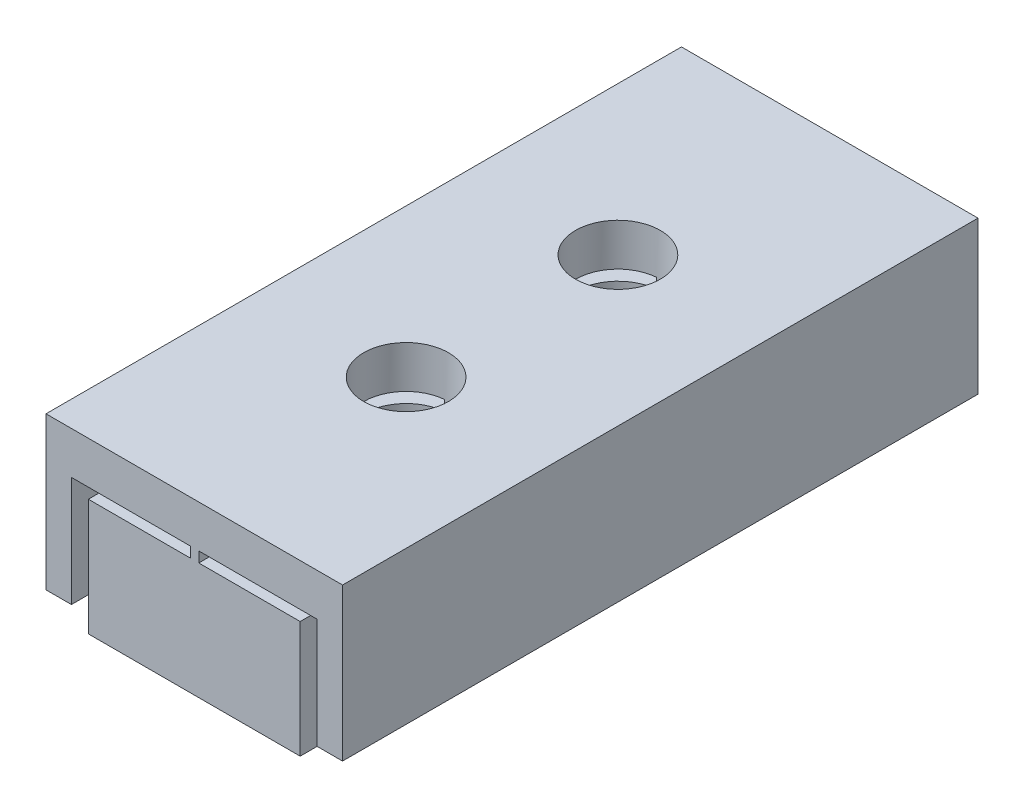
from build123d import *

# Parameters (mm, degrees)
SKETCH_1_W          = 5
SKETCH_1_H          = 15
EXTRUDE_1_DEPTH     = 3
EXTRUDE_2_DEPTH     = 15
SKETCH_3_R          = 1
CUT_EXTRUDE_1_DEPTH = 5
SKETCH_5_W          = 2.409632894
SKETCH_5_H          = 0.246400488
SKETCH_5_W_2        = 2.393250689
CUT_EXTRUDE_3_DEPTH = 15
SKETCH_6_W          = 0.6
SKETCH_6_H          = 0.4
CUT_EXTRUDE_4_DEPTH = 15


with BuildPart() as part:
    # 草图1 → 凸台-拉伸1 (new body)
    with BuildSketch(Plane(origin=(0, 0, 0), x_dir=(1, 0, 0), z_dir=(0, 1, 0))):
        with Locations((-2.5, -7.5)):
            Rectangle(SKETCH_1_W, SKETCH_1_H)
    extrude(amount=EXTRUDE_1_DEPTH)

    # 草图2 → 凸台-拉伸2 (add)
    with BuildSketch(Plane(origin=(0, 0, 0), x_dir=(-1, 0, 0), z_dir=(0, 0, -1))):
        Polygon((-0.4, 0), (-0.4, 3), (5.4, 3), (5.4, 0), (6, 0), (6, 4), (-1, 4), (-1, 0), align=None)
    extrude(amount=-EXTRUDE_2_DEPTH)

    # 草图3 → 切除-拉伸1 (cut, through all)
    with BuildSketch(Plane(origin=(0, 4, 0), x_dir=(1, 0, 0), z_dir=(0, 1, 0))):
        with Locations((-2.5, -10)):
            Circle(SKETCH_3_R)
        with Locations((-2.5, -5)):
            Circle(SKETCH_3_R)
    extrude(amount=-CUT_EXTRUDE_1_DEPTH, mode=Mode.SUBTRACT)

    # 草图5 → 切除-拉伸3 (cut)
    with BuildSketch(Plane.XY.offset(15)):
        with Locations((-3.795183553, 2.876799756)):
            Rectangle(SKETCH_5_W, SKETCH_5_H)
        with Locations((-1.196625345, 2.876799756)):
            Rectangle(SKETCH_5_W_2, SKETCH_5_H)
    extrude(amount=-CUT_EXTRUDE_3_DEPTH, mode=Mode.SUBTRACT)

    # 草图6 → 切除-拉伸4 (cut)
    with BuildSketch(Plane(origin=(0, 0, 0), x_dir=(-1, 0, 0), z_dir=(0, 0, -1))):
        with Locations((-0.7, 0.2)):
            Rectangle(SKETCH_6_W, SKETCH_6_H)
        with Locations((5.7, 0.2)):
            Rectangle(SKETCH_6_W, SKETCH_6_H)
    extrude(amount=-CUT_EXTRUDE_4_DEPTH, mode=Mode.SUBTRACT)


solid = part.part
